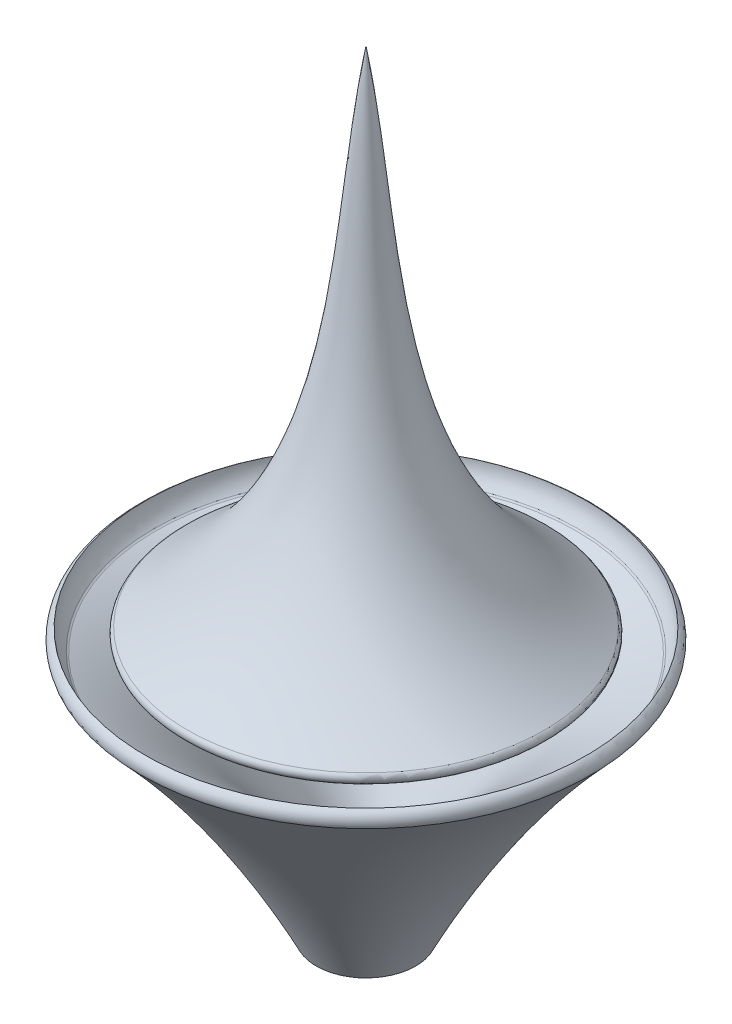
from build123d import *

# Parameters (mm, degrees)
FILLET2_R = 1
FILLET3_R = 1


with BuildPart() as part:
    # Sketch1 → Revolve1 (revolve)
    with BuildSketch(Plane.XY):
        with BuildLine():
            Line((-33.462228882, 0), (0, 0))
            Line((0, 0), (0, 88.202070694))
            add(Edge.make_bspline(
                [(0, 88.202070694), (-5.406695838, 57.59866809), (-1.679685214, 19.194799647), (-33.462228882, 0)],
                knots=[0, 0, 0, 0, 1, 1, 1, 1], degree=3))
        make_face()
    revolve(axis=Axis((0, 0, 0), (0, 1, 0)))

    # Fillet3
    fillet3_edges = [part.edges().sort_by_distance(p)[0] for p in [
        (33.462228882, 0, 0),
    ]]
    fillet(fillet3_edges, radius=FILLET3_R)


with BuildPart() as body_2:
    # Sketch2 → Revolve3 (revolve)
    with BuildSketch(Plane.XY):
        with BuildLine():
            Line((-8.534646324, -44.287710663), (-3.524009755, -44.287710663))
            Line((-3.524009755, -44.287710663), (-3.524009755, -35.924904385))
            add(Edge.make_bspline(
                [(-36.2496445, -1.846831826), (-23.743909654, -7.82050731), (-12.013985883, -19.859684859), (-4.443283638, -34.036963197), (-3.524009755, -35.924904385)],
                knots=[0, 0, 0, 0, 0.729675534, 0.839930538, 0.839930538, 0.839930538, 0.839930538], degree=3))
            add(Edge.make_bspline(
                [(-36.2496445, -1.846831826), (-37.772690493, -0.385439184), (-37.859600545, 1.685548125)],
                knots=[0, 0, 0, 1, 1, 1], degree=2))
            ThreePointArc((-37.859600545, 1.685548125), (-38.736688816, 0.591049714), (-38.652717905, -0.809007246))
            add(Edge.make_bspline(
                [(-38.652717905, -0.809007246), (-20.408034979, -20.206042361), (-8.534646324, -44.287710663)],
                knots=[0, 0, 0, 1, 1, 1], degree=2))
        make_face()
    revolve(axis=Axis((0, 0, 0), (0, 1, 0)))

    # Fillet2
    fillet2_edges = [body_2.edges().sort_by_distance(p)[0] for p in [
        (36.2496445, -1.846831826, 0),
        (3.524009755, -35.924904385, 0),
        (3.524009755, -44.287710663, 0),
    ]]
    fillet(fillet2_edges, radius=FILLET2_R)


solid = Compound([part.part, body_2.part])
